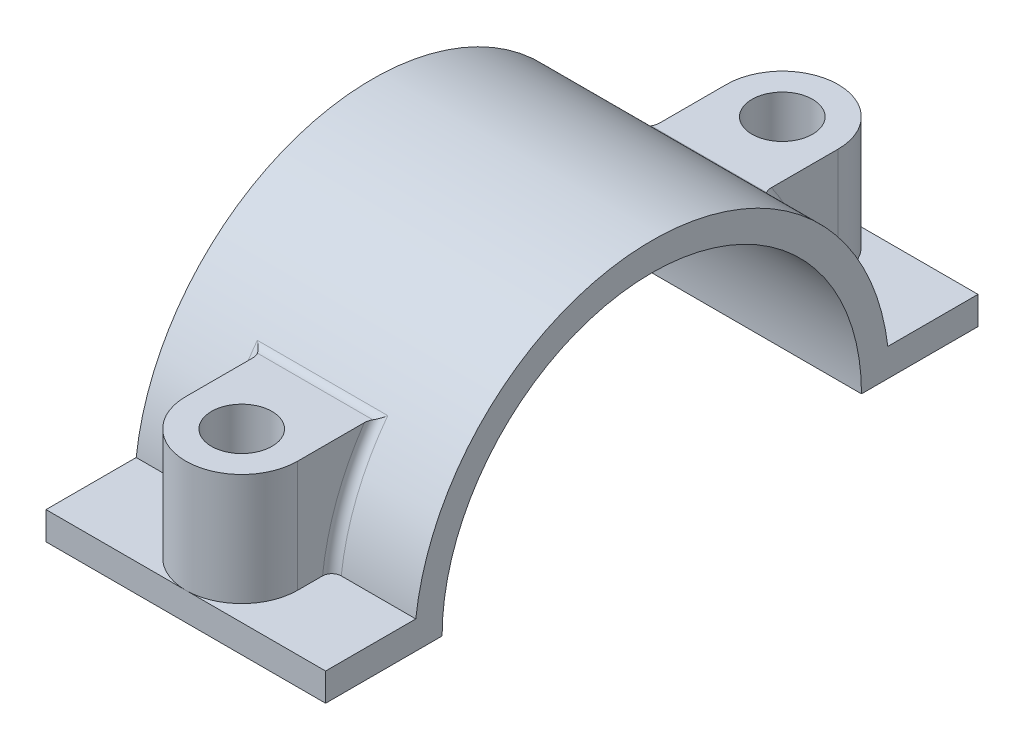
from build123d import *

# Parameters (mm, degrees)
BOSS_EXTRUDE1_DEPTH = 15
BOSS_EXTRUDE2_REACH = 42.927
SKETCH3_R           = 3.25
CUT_EXTRUDE1_DEPTH  = 41.926763859
FILLET1_R           = 1


with BuildPart() as part:
    # Sketch1 → Boss-Extrude1 (new, symmetric)
    with BuildSketch(Plane(origin=(0, 0, 0), x_dir=(0, 0, -1), z_dir=(1, 0, 0))):
        with BuildLine():
            Line((-22.5, 0), (-35, 0))
            Line((-35, 0), (-35, 3))
            Line((-35, 3), (-25.322914524, 3))
            ThreePointArc((-25.322914524, 3), (0, 25.5), (25.322914524, 3))
            Line((25.322914524, 3), (35, 3))
            Line((35, 3), (35, 0))
            Line((35, 0), (22.5, 0))
            ThreePointArc((22.5, 0), (0, 22.5), (-22.5, 0))
        make_face()
    extrude(amount=BOSS_EXTRUDE1_DEPTH, both=True)

    # Sketch2 → Boss-Extrude2 (add, up to next)
    with BuildSketch(Plane(origin=(0, 15, 0), x_dir=(1, 0, 0), z_dir=(0, 1, 0)), mode=Mode.PRIVATE) as boss_extrude2_sk1:
        with BuildLine():
            Line((-6, -29), (-6, -19))
            Line((-6, -19), (6, -19))
            Line((6, -19), (6, -29))
            ThreePointArc((6, -29), (0, -35), (-6, -29))
        make_face()
    boss_extrude2_tool1 = extrude(boss_extrude2_sk1.sketch, amount=-BOSS_EXTRUDE2_REACH, mode=Mode.PRIVATE) - part.part
    boss_extrude2 = boss_extrude2_tool1.solids().sort_by_distance((0, 15, 26.417143))[0]
    add(boss_extrude2)

    # Sketch3 → Cut-Extrude1 (cut, through all)
    with BuildSketch(Plane(origin=(0, 15, 0), x_dir=(1, 0, 0), z_dir=(0, 1, 0))):
        with Locations(Location((0, -29, 0), (0, 0, 270))):
            Circle(SKETCH3_R)
    cut_extrude1 = extrude(amount=-CUT_EXTRUDE1_DEPTH, mode=Mode.SUBTRACT)

    # Mirror1: Boss-Extrude2, Cut-Extrude1 across plane
    add(boss_extrude2.mirror(Plane.XY))
    add(cut_extrude1.mirror(Plane.XY), mode=Mode.SUBTRACT)

    # Fillet1
    fillet1_edges = [part.edges().sort_by_distance(p)[0] for p in [
        (-6, 9.301914405, 23.742880794),
        (6, 9.301914405, 23.742880794),
        (0, 15, 20.621590627),
        (-6, 9.301914405, -23.742880794),
        (6, 9.301914405, -23.742880794),
        (0, 15, -20.621590627),
    ]]
    fillet(fillet1_edges, radius=FILLET1_R)


solid = part.part
